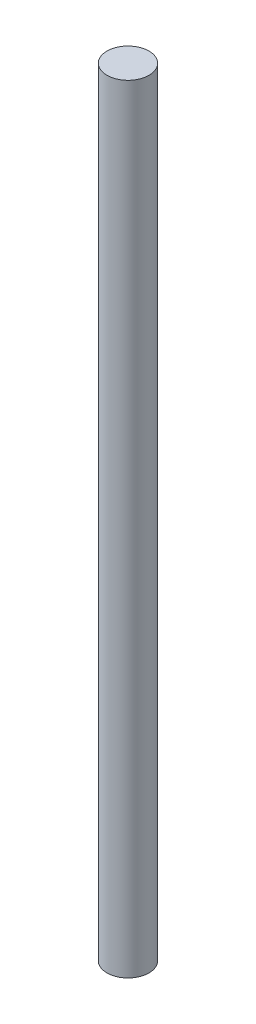
from build123d import *

# Parameters (mm, degrees)
SKETCH1_R           = 0.5
BOSS_EXTRUDE1_DEPTH = 9.25


with BuildPart() as part:
    # Sketch1 → Boss-Extrude1 (new body, symmetric)
    with BuildSketch(Plane(origin=(0, 0, 0), x_dir=(1, 0, 0), z_dir=(0, 1, 0))):
        Circle(SKETCH1_R)
    extrude(amount=BOSS_EXTRUDE1_DEPTH, both=True)


solid = part.part
